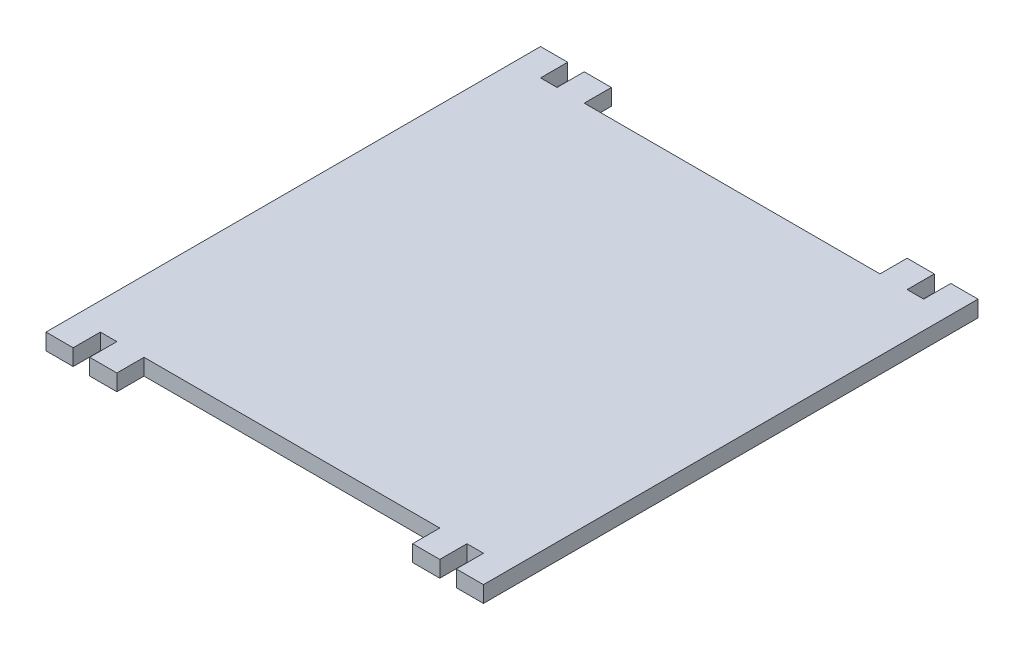
from build123d import *

# Parameters (mm, degrees)
SKETCH1_W           = 70.5
SKETCH1_H           = 81
BOSS_EXTRUDE1_DEPTH = 3
SKETCH2_W           = 5
SKETCH2_H           = 3
BOSS_EXTRUDE2_DEPTH = 5
SKETCH3_W           = 5
SKETCH3_H           = 3
BOSS_EXTRUDE3_DEPTH = 5
BOSS_EXTRUDE4_DEPTH = 3


with BuildPart() as part:
    # Sketch1 → Boss-Extrude1 (new body)
    with BuildSketch(Plane(origin=(0, 0, 0), x_dir=(1, 0, 0), z_dir=(0, 1, 0))):
        with Locations((35.25, -40.5)):
            Rectangle(SKETCH1_W, SKETCH1_H)
    extrude(amount=BOSS_EXTRUDE1_DEPTH)

    # Sketch2 → Boss-Extrude2 (add)
    with BuildSketch(Plane.XY.offset(81)):
        with Locations((5.54, 1.5)):
            Rectangle(SKETCH2_W, SKETCH2_H)
        with Locations((64.96, 1.5)):
            Rectangle(SKETCH2_W, SKETCH2_H)
    extrude(amount=BOSS_EXTRUDE2_DEPTH)

    # Sketch3 → Boss-Extrude3 (add)
    with BuildSketch(Plane(origin=(0, 0, 0), x_dir=(-1, 0, 0), z_dir=(0, 0, -1))):
        with Locations((-5.54, 1.5)):
            Rectangle(SKETCH3_W, SKETCH3_H)
        with Locations((-64.96, 1.5)):
            Rectangle(SKETCH3_W, SKETCH3_H)
    extrude(amount=BOSS_EXTRUDE3_DEPTH)

    # Sketch4 → Boss-Extrude4 (add)
    with BuildSketch(Plane(origin=(0, 3, 0), x_dir=(1, 0, 0), z_dir=(0, 1, 0))):
        Polygon((0, 0), (0, 5), (-5, 5), (-5, -86), (0, -86), (0, -81), align=None)
        Polygon((70.5, 5), (70.5, 0), (70.5, -81), (70.5, -86), (75.5, -86), (75.5, 0), (75.5, 5), align=None)
    extrude(amount=-BOSS_EXTRUDE4_DEPTH)


solid = part.part
